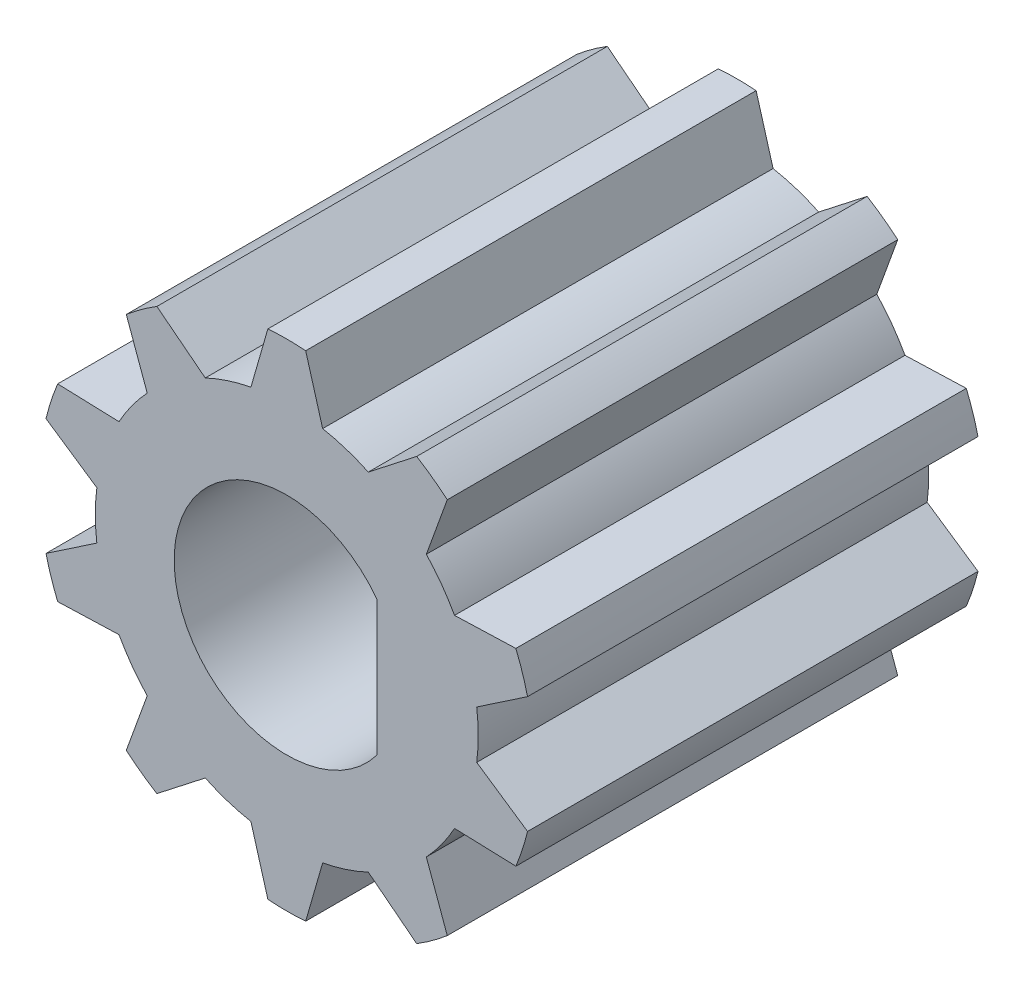
from build123d import *

# Parameters (mm, degrees)
BOSS_EXTRUDE1_DEPTH = 10


with BuildPart() as part:
    # Sketch1 → Boss-Extrude1 (new body)
    with BuildSketch(Plane.XY):
        with BuildLine():
            Line((-0.796448866, 4.174705882), (-0.41969374, 5.483963636))
            ThreePointArc((-0.41969374, 5.483963636), (0, 5.5), (0.41969374, 5.483963636))
            Line((0.41969374, 5.483963636), (0.796448866, 4.174705882))
            ThreePointArc((0.796448866, 4.174705882), (1.313322226, 4.041990194), (1.809489883, 3.845548903))
            Line((1.809489883, 3.845548903), (2.883853582, 4.683309569))
            ThreePointArc((2.883853582, 4.683309569), (3.232818888, 4.449593469), (3.562932317, 4.189929988))
            Line((3.562932317, 4.189929988), (3.098171218, 2.909267108))
            ThreePointArc((3.098171218, 2.909267108), (3.438322226, 2.498087322), (3.724264998, 2.047522948))
            Line((3.724264998, 2.047522948), (5.085866854, 2.093790426))
            ThreePointArc((5.085866854, 2.093790426), (5.23081084, 1.699593469), (5.345251849, 1.295485494))
            Line((5.345251849, 1.295485494), (4.216497468, 0.53258718))
            ThreePointArc((4.216497468, 0.53258718), (4.25, 0), (4.216497468, -0.53258718))
            Line((4.216497468, -0.53258718), (5.345251849, -1.295485494))
            ThreePointArc((5.345251849, -1.295485494), (5.23081084, -1.699593469), (5.085866854, -2.093790426))
            Line((5.085866854, -2.093790426), (3.724264998, -2.047522948))
            ThreePointArc((3.724264998, -2.047522948), (3.438322226, -2.498087322), (3.098171218, -2.909267108))
            Line((3.098171218, -2.909267108), (3.562932317, -4.189929988))
            ThreePointArc((3.562932317, -4.189929988), (3.232818888, -4.449593469), (2.883853582, -4.683309569))
            Line((2.883853582, -4.683309569), (1.809489883, -3.845548903))
            ThreePointArc((1.809489883, -3.845548903), (1.313322226, -4.041990194), (0.796448866, -4.174705882))
            Line((0.796448866, -4.174705882), (0.41969374, -5.483963636))
            ThreePointArc((0.41969374, -5.483963636), (0, -5.5), (-0.41969374, -5.483963636))
            Line((-0.41969374, -5.483963636), (-0.796448866, -4.174705882))
            ThreePointArc((-0.796448866, -4.174705882), (-1.313322226, -4.041990194), (-1.809489883, -3.845548903))
            Line((-1.809489883, -3.845548903), (-2.883853582, -4.683309569))
            ThreePointArc((-2.883853582, -4.683309569), (-3.232818888, -4.449593469), (-3.562932317, -4.189929988))
            Line((-3.562932317, -4.189929988), (-3.098171218, -2.909267108))
            ThreePointArc((-3.098171218, -2.909267108), (-3.438322226, -2.498087322), (-3.724264998, -2.047522948))
            Line((-3.724264998, -2.047522948), (-5.085866854, -2.093790426))
            ThreePointArc((-5.085866854, -2.093790426), (-5.23081084, -1.699593469), (-5.345251849, -1.295485494))
            Line((-5.345251849, -1.295485494), (-4.216497468, -0.53258718))
            ThreePointArc((-4.216497468, -0.53258718), (-4.25, 0), (-4.216497468, 0.53258718))
            Line((-4.216497468, 0.53258718), (-5.345251849, 1.295485494))
            ThreePointArc((-5.345251849, 1.295485494), (-5.23081084, 1.699593469), (-5.085866854, 2.093790426))
            Line((-5.085866854, 2.093790426), (-3.724264998, 2.047522948))
            ThreePointArc((-3.724264998, 2.047522948), (-3.438322226, 2.498087322), (-3.098171218, 2.909267108))
            Line((-3.098171218, 2.909267108), (-3.562932317, 4.189929988))
            ThreePointArc((-3.562932317, 4.189929988), (-3.232818888, 4.449593469), (-2.883853582, 4.683309569))
            Line((-2.883853582, 4.683309569), (-1.809489883, 3.845548903))
            ThreePointArc((-1.809489883, 3.845548903), (-1.313322226, 4.041990194), (-0.796448866, 4.174705882))
        make_face()
        with BuildLine():
            Line((2, 1.5), (2, -1.5))
            ThreePointArc((2, -1.5), (-2.5, 0), (2, 1.5))
        make_face(mode=Mode.SUBTRACT)
    extrude(amount=BOSS_EXTRUDE1_DEPTH)


solid = part.part
